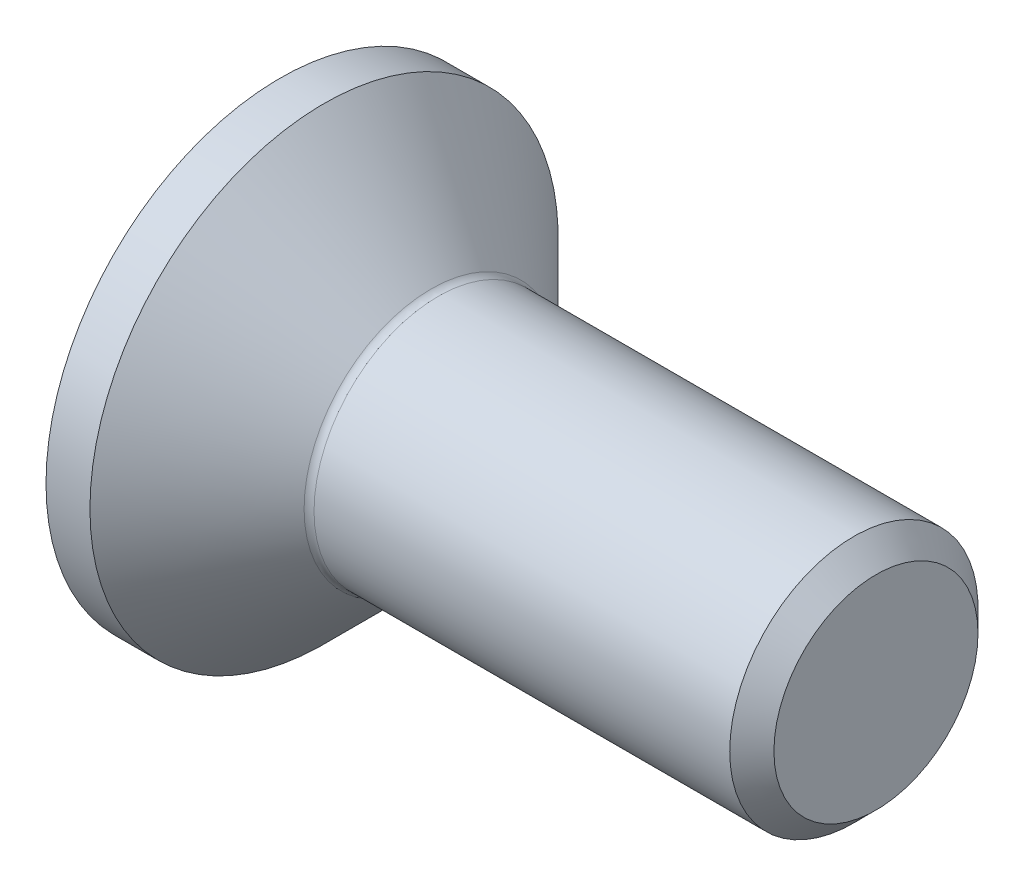
from build123d import *

# Parameters (mm, degrees)
FILLET1_R   = 0.2
HEX_2_DEPTH = 1.9


with BuildPart() as part:
    # BodySke → BaseBody (revolve)
    with BuildSketch(Plane.XY):
        Polygon((0, 0), (0, 4.715), (0.885, 4.715), (3.1, 2.5), (11.555, 2.5), (12, 2.055), (12, 0), align=None)
    revolve(axis=Axis((0, 0, 0), (1, 0, 0)))

    # Fillet1
    fillet1_edges = [part.edges().sort_by_distance(p)[0] for p in [
        (3.1, -2.5, 0),
    ]]
    fillet(fillet1_edges, radius=FILLET1_R)

    # Sketch2 → PreBroach (revolve, cut)
    with BuildSketch(Plane.XY):
        Polygon((0, 1.5), (1.9, 1.5), (2.766025404, 0), (0, 0), align=None)
    revolve(axis=Axis((0, 0, 0), (1, 0, 0)), mode=Mode.SUBTRACT)

    # Sketch3 → Hex 2 (cut)
    with BuildSketch(Plane.ZY):
        Polygon((-1.5, -0.866025404), (-1.5, 0.866025404), (0, 1.732050808), (1.5, 0.866025404), (1.5, -0.866025404), (0, -1.732050808), align=None)
    extrude(amount=-HEX_2_DEPTH, mode=Mode.SUBTRACT)


solid = part.part
